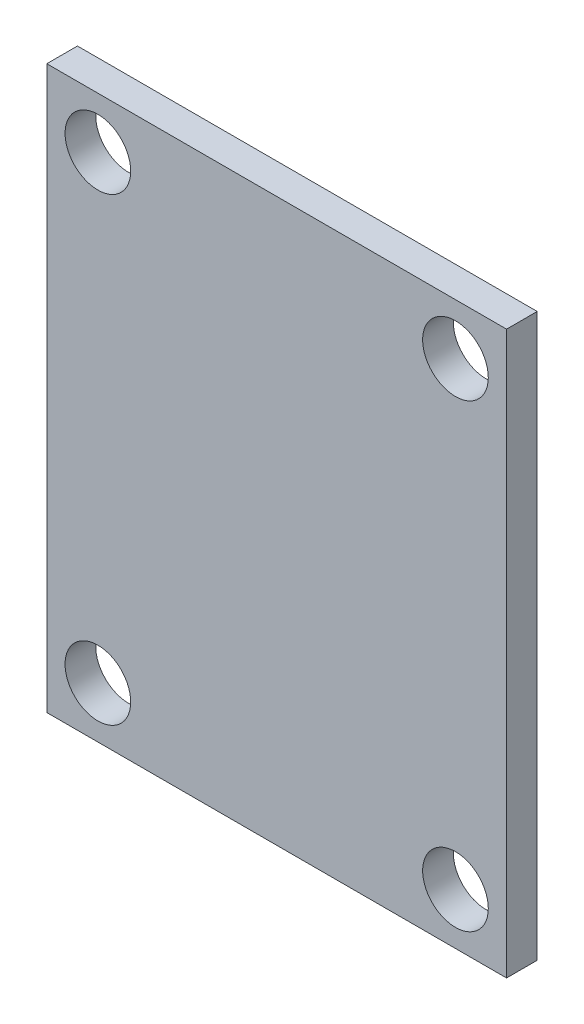
from build123d import *

# Parameters (mm, degrees)
SKETCH1_W           = 22.86
SKETCH1_H           = 27.94
SKETCH1_R           = 1.63195
BOSS_EXTRUDE1_DEPTH = 1.524


with BuildPart() as part:
    # Sketch1 → Boss-Extrude1 (new body)
    with BuildSketch(Plane.XY):
        Rectangle(SKETCH1_W, SKETCH1_H)
        with Locations((-8.89, 11.43)):
            Circle(SKETCH1_R, mode=Mode.SUBTRACT)
        with Locations((8.89, 11.43)):
            Circle(SKETCH1_R, mode=Mode.SUBTRACT)
        with Locations((8.89, -11.43)):
            Circle(SKETCH1_R, mode=Mode.SUBTRACT)
        with Locations((-8.89, -11.43)):
            Circle(SKETCH1_R, mode=Mode.SUBTRACT)
    extrude(amount=BOSS_EXTRUDE1_DEPTH)


solid = part.part
